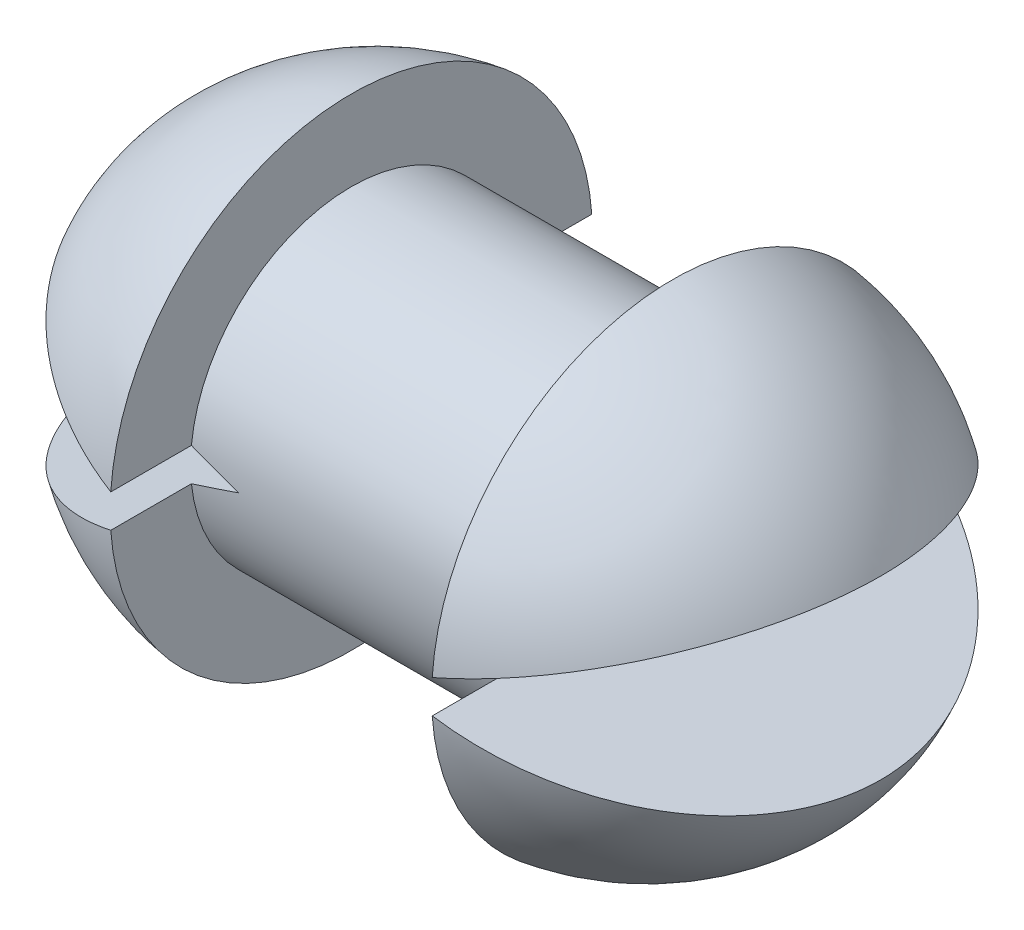
from build123d import *

# Parameters (mm, degrees)
CUT_EXTRUDE1_DEPTH = 20


with BuildPart() as part:
    # Sketch1 → Revolve4 (revolve)
    with BuildSketch(Plane.XY):
        with BuildLine():
            Line((-10, 10), (-10, 15))
            ThreePointArc((-10, 15), (-19.821538313, 9.985820369), (-24.5, 0))
            Line((-24.5, 0), (-7, 0))
            Line((-7, 0), (7, 0))
            Line((7, 0), (24.5, 0))
            ThreePointArc((24.5, 0), (19.821538313, 9.985820369), (10, 15))
            Line((10, 15), (10, 10))
            Line((10, 10), (-10, 10))
        make_face()
    revolve(axis=Axis((-3.122498999, 0, 0), (1, 0, 0)))

    # Sketch2 → Cut-Extrude1 (cut, symmetric)
    with BuildSketch(Plane.XY):
        Polygon((-25, 0), (-7, 0), (-24.964852936, -6.185794935), align=None)
        Polygon((-24.964852936, 6.185794935), (-25, 0), (-7, 0), align=None)
        Polygon((25, 0), (7, 0), (24.964852936, 6.185794935), align=None)
        Polygon((25, 0), (7, 0), (24.964852936, -6.185794935), align=None)
    extrude(amount=CUT_EXTRUDE1_DEPTH, both=True, mode=Mode.SUBTRACT)


solid = part.part
